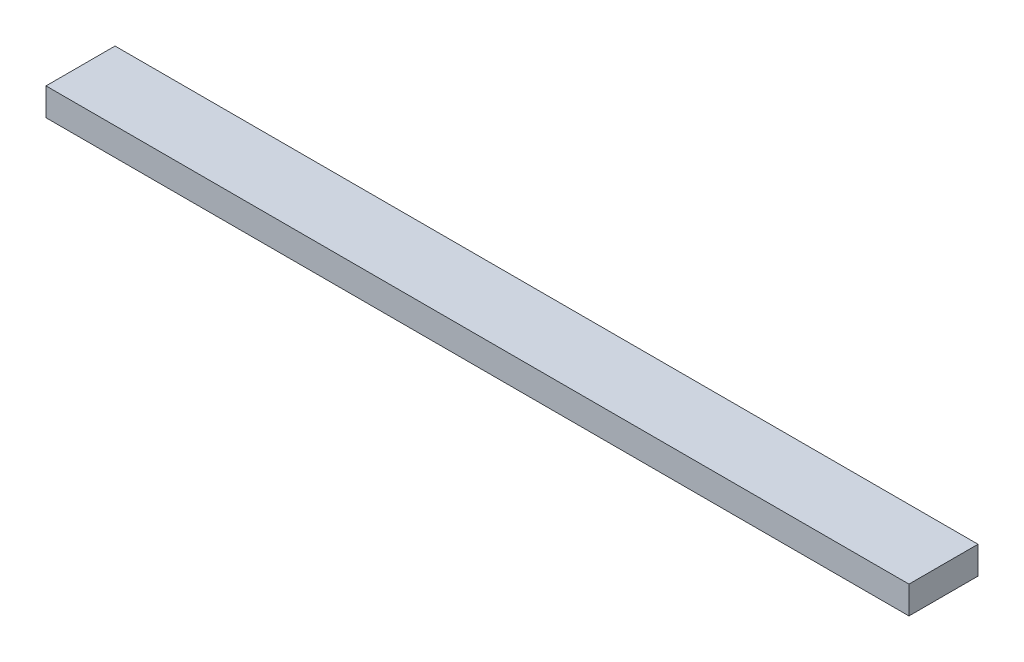
from build123d import *

# Parameters (mm, degrees)
SKETCH_1_W      = 50
SKETCH_1_H      = 4
EXTRUDE_1_DEPTH = 1.6


with BuildPart() as part:
    # Эскиз1 → Бобышка-Вытянуть1 (new body)
    with BuildSketch(Plane(origin=(0, 0, 0), x_dir=(1, 0, 0), z_dir=(0, 1, 0))):
        Rectangle(SKETCH_1_W, SKETCH_1_H)
    extrude(amount=EXTRUDE_1_DEPTH)


solid = part.part
